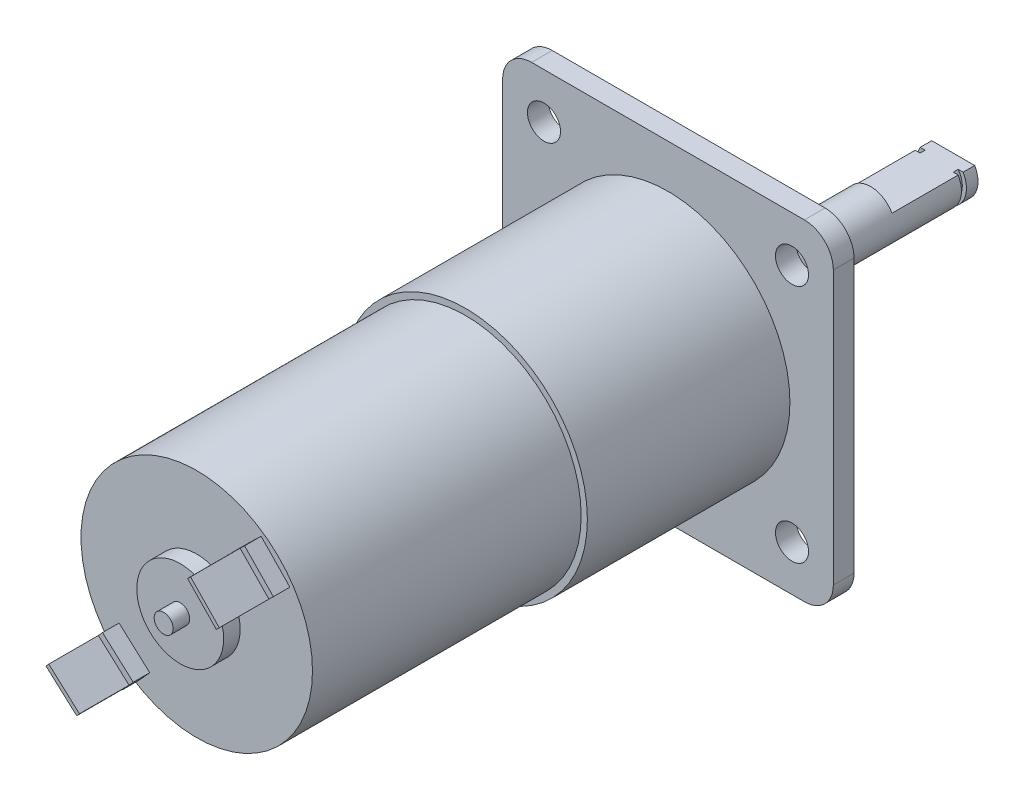
from build123d import *

# Parameters (mm, degrees)
CROQUIS1_R              = 3
SALIENTE_EXTRUIR1_DEPTH = 20
CROQUIS3_R              = 6.5
SALIENTE_EXTRUIR2_DEPTH = 12
CROQUIS4_R              = 2
SALIENTE_EXTRUIR3_DEPTH = 2.5
CROQUIS5_R              = 14.75
SALIENTE_EXTRUIR4_DEPTH = 24.5
CROQUIS6_R              = 14
SALIENTE_EXTRUIR5_DEPTH = 32.5
CROQUIS7_R              = 5.25
SALIENTE_EXTRUIR6_DEPTH = 2
CROQUIS8_R              = 1.15
SALIENTE_EXTRUIR7_DEPTH = 2
SALIENTE_EXTRUIR8_DEPTH = 2
SALIENTE_EXTRUIR9_DEPTH = 6
CORTAR_EXTRUIR1_DEPTH   = 10
CROQUIS12_W             = 0.5
CROQUIS12_H             = 0.6


with BuildPart() as part:
    # Croquis1 → Saliente-Extruir1 (new body)
    with BuildSketch(Plane.XY):
        Circle(CROQUIS1_R)
    extrude(amount=SALIENTE_EXTRUIR1_DEPTH)

    # Croquis3 → Saliente-Extruir2 (add)
    with BuildSketch(Plane.XY.offset(20)):
        Circle(CROQUIS3_R)
    extrude(amount=SALIENTE_EXTRUIR2_DEPTH)

    # Croquis4 → Saliente-Extruir3 (add)
    with BuildSketch(Plane.XY.offset(32)):
        with BuildLine():
            Line((16.5, -20), (-16.5, -20))
            ThreePointArc((-16.5, -20), (-18.974873734, -18.974873734), (-20, -16.5))
            Line((-20, -16.5), (-20, 16.5))
            ThreePointArc((-20, 16.5), (-18.974873734, 18.974873734), (-16.5, 20))
            Line((-16.5, 20), (16.5, 20))
            ThreePointArc((16.5, 20), (18.974873734, 18.974873734), (20, 16.5))
            Line((20, 16.5), (20, -16.5))
            ThreePointArc((20, -16.5), (18.974873734, -18.974873734), (16.5, -20))
        make_face()
        with Locations((15, 14.5)):
            Circle(CROQUIS4_R, mode=Mode.SUBTRACT)
        with Locations((15, -14.5)):
            Circle(CROQUIS4_R, mode=Mode.SUBTRACT)
        with Locations((-15, -14.5)):
            Circle(CROQUIS4_R, mode=Mode.SUBTRACT)
        with Locations((-15, 14.5)):
            Circle(CROQUIS4_R, mode=Mode.SUBTRACT)
    extrude(amount=SALIENTE_EXTRUIR3_DEPTH)

    # Croquis5 → Saliente-Extruir4 (add)
    with BuildSketch(Plane.XY.offset(34.5)):
        Circle(CROQUIS5_R)
    extrude(amount=SALIENTE_EXTRUIR4_DEPTH)

    # Croquis6 → Saliente-Extruir5 (add)
    with BuildSketch(Plane.XY.offset(59)):
        Circle(CROQUIS6_R)
    extrude(amount=SALIENTE_EXTRUIR5_DEPTH)

    # Croquis7 → Saliente-Extruir6 (add)
    with BuildSketch(Plane.XY.offset(91.5)):
        Circle(CROQUIS7_R)
    extrude(amount=SALIENTE_EXTRUIR6_DEPTH)

    # Croquis8 → Saliente-Extruir7 (add)
    with BuildSketch(Plane.XY.offset(93.5)):
        Circle(CROQUIS8_R)
    extrude(amount=SALIENTE_EXTRUIR7_DEPTH)

    # Croquis9 → Saliente-Extruir8 (add)
    with BuildSketch(Plane.XY.offset(91.5)):
        Polygon((8.088619231, 7.81899859), (6.351063988, 9.61646953), (7.789040741, 11.006513723), (9.526595983, 9.209042783), (11.264151225, 7.411571843), (9.826174473, 6.021527649), align=None)
        Polygon((-9.395717522, -6.673304447), (-10.736232323, -8.15756186), (-8.880910557, -9.833205361), (-7.025588791, -11.508848863), (-5.68507399, -10.02459145), (-7.540395756, -8.348947948), align=None)
    extrude(amount=SALIENTE_EXTRUIR8_DEPTH)

    # Croquis10 → Saliente-Extruir9 (add)
    with BuildSketch(Plane.XY.offset(93.5)):
        Polygon((-6.18776704, -10.581187979), (-9.898410573, -7.229900977), (-10.233539273, -7.60096533), (-6.52289574, -10.952252333), align=None)
        Polygon((6.89030527, 10.137736102), (7.249799458, 10.485247151), (10.724909943, 6.89030527), (10.365415755, 6.542794222), align=None)
    extrude(amount=SALIENTE_EXTRUIR9_DEPTH)

    # Croquis11 → Cortar-Extruir1 (cut)
    with BuildSketch(Plane(origin=(0, 0, 0), x_dir=(-1, 0, 0), z_dir=(0, 0, -1))):
        with BuildLine():
            Line((-2.598076211, 1.5), (2.598076211, 1.5))
            ThreePointArc((2.598076211, 1.5), (0, 3), (-2.598076211, 1.5))
        make_face()
    extrude(amount=-CORTAR_EXTRUIR1_DEPTH, mode=Mode.SUBTRACT)

    # Croquis12 → Cortar-Revolución1 (revolve, cut)
    with BuildSketch(Plane(origin=(0, 0, 0), x_dir=(1, 0, 0), z_dir=(0, 1, 0))):
        with Locations((-2.75, -1.7)):
            Rectangle(CROQUIS12_W, CROQUIS12_H)
    revolve(axis=Axis((0, 0, 20), (0, 0, -1)), mode=Mode.SUBTRACT)


solid = part.part
